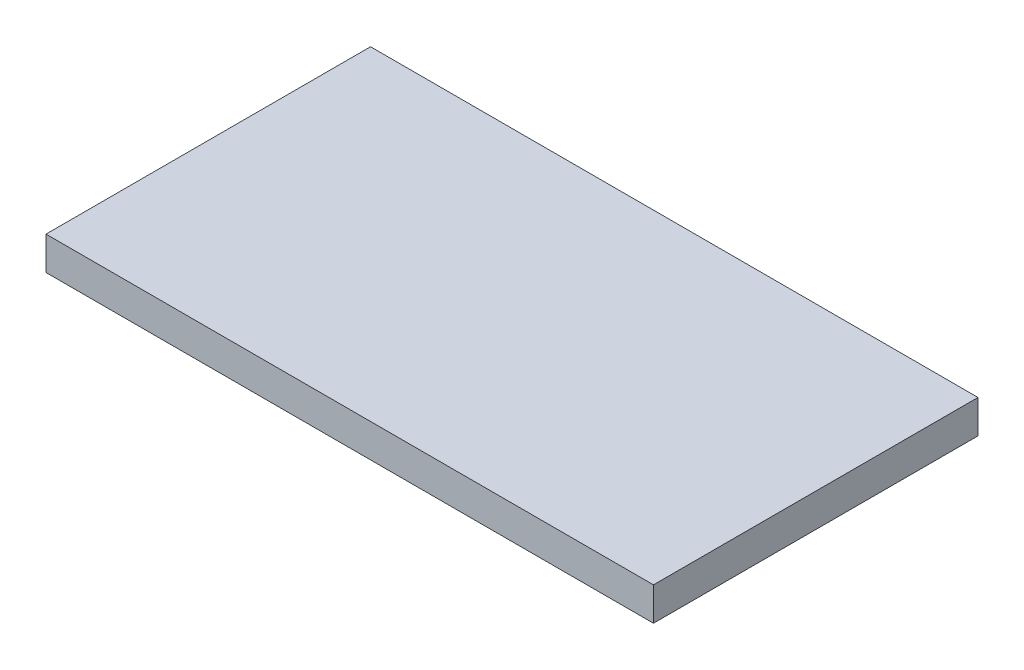
from build123d import *

# Parameters (mm, degrees)
ESBO_O1_W                = 36.5
ESBO_O1_H                = 19.5
RESSALTO_EXTRUS_O1_DEPTH = 2


with BuildPart() as part:
    # Esboço1 → Ressalto-extrusão1 (new body)
    with BuildSketch(Plane(origin=(0, 0, 0), x_dir=(1, 0, 0), z_dir=(0, 1, 0))):
        Rectangle(ESBO_O1_W, ESBO_O1_H)
    extrude(amount=RESSALTO_EXTRUS_O1_DEPTH)


solid = part.part
